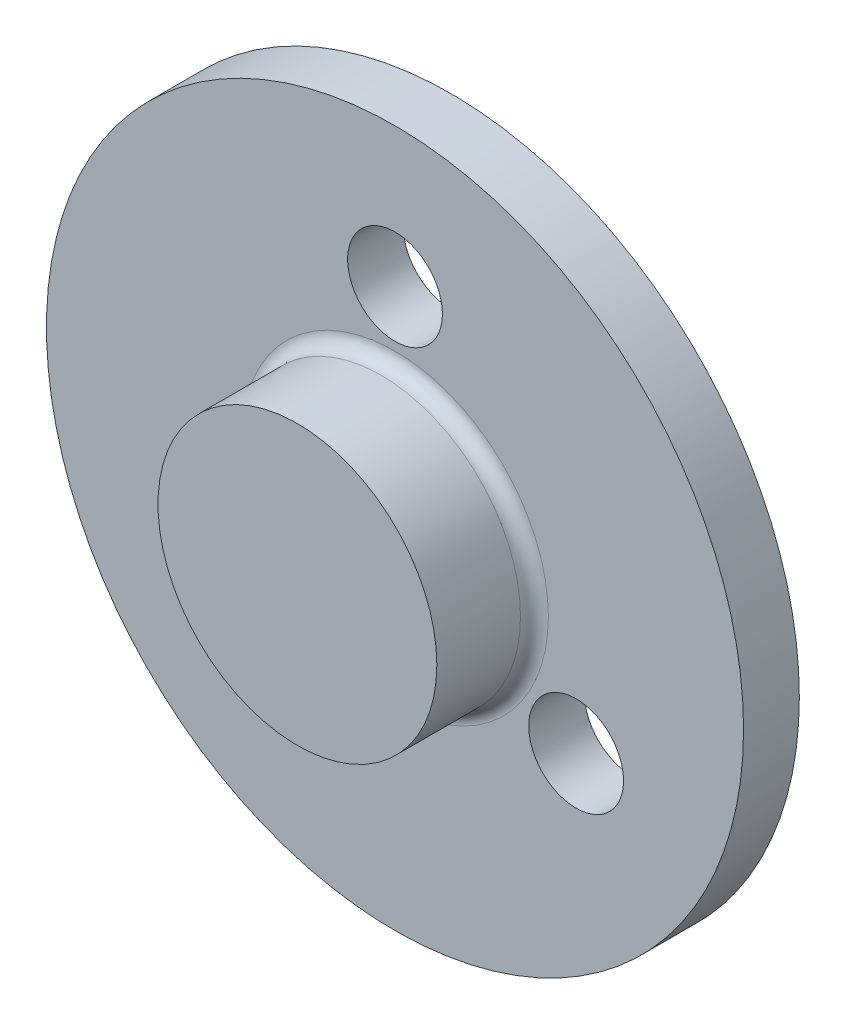
from build123d import *

# Parameters (mm, degrees)
SKETCH1_R             = 25
BOSS_EXTRUDE1_DEPTH   = 4
SKETCH2_R             = 10
BOSS_EXTRUDE2_DEPTH   = 7
FILLET1_R             = 1
SKETCH3_R             = 7.5
CUT_EXTRUDE1_DEPTH    = 5
F_6_0MM_DOWEL_HOLE1_D = 6.8


with BuildPart() as part:
    # Sketch1 → Boss-Extrude1 (new body)
    with BuildSketch(Plane.XY):
        Circle(SKETCH1_R)
    extrude(amount=-BOSS_EXTRUDE1_DEPTH)

    # Sketch2 → Boss-Extrude2 (add)
    with BuildSketch(Plane.XY):
        Circle(SKETCH2_R)
    extrude(amount=BOSS_EXTRUDE2_DEPTH)

    # Fillet1
    fillet1_edges = [part.edges().sort_by_distance(p)[0] for p in [
        (-10, 0, 0),
    ]]
    fillet(fillet1_edges, radius=FILLET1_R)

    # Sketch3 → Cut-Extrude1 (cut)
    with BuildSketch(Plane(origin=(0, 0, -4), x_dir=(-1, 0, 0), z_dir=(0, 0, -1))):
        Circle(SKETCH3_R)
    extrude(amount=-CUT_EXTRUDE1_DEPTH, mode=Mode.SUBTRACT)

    # Ø6.0mm Dowel Hole1 (through all)
    with Locations(Plane.XY):
        with Locations((-12.990381057, -7.5), (0, 15), (12.990381057, -7.5)):
            Hole(F_6_0MM_DOWEL_HOLE1_D / 2)


solid = part.part
